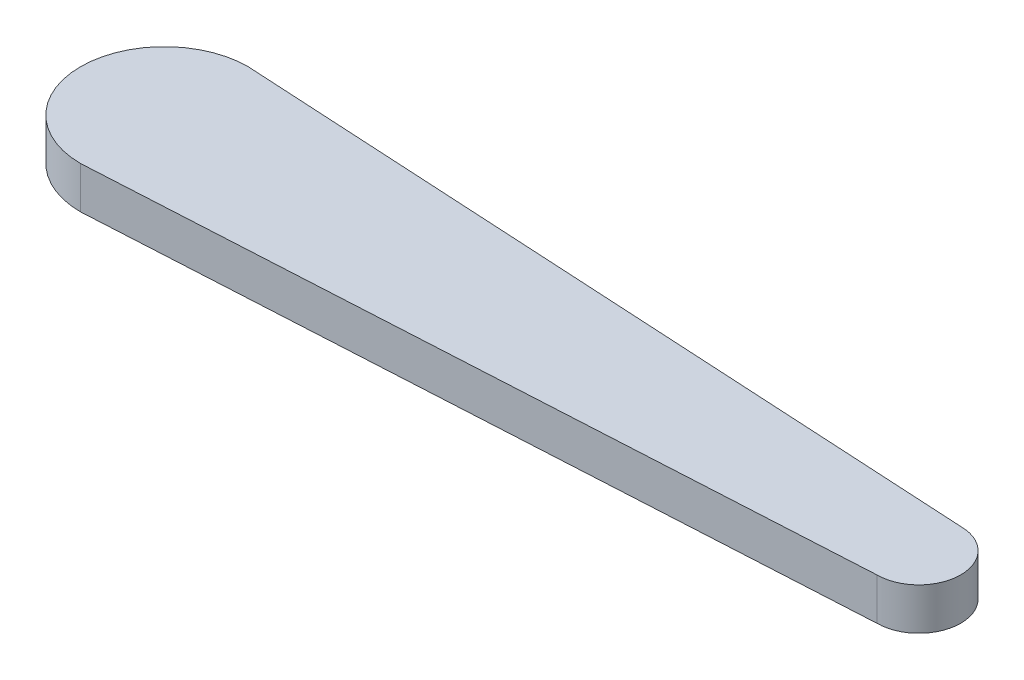
from build123d import *

# Parameters (mm, degrees)
BOSS_EXTRUDE1_DEPTH = 5


with BuildPart() as part:
    # Sketch1 → Boss-Extrude1 (new body)
    with BuildSketch(Plane(origin=(0, 0, 0), x_dir=(1, 0, 0), z_dir=(0, 1, 0))):
        with BuildLine():
            Line((0, 10), (90, 5))
            ThreePointArc((90, 5), (95, 0), (90, -5))
            Line((90, -5), (0, -10))
            ThreePointArc((0, -10), (-10, 0), (0, 10))
        make_face()
    extrude(amount=BOSS_EXTRUDE1_DEPTH)


solid = part.part
